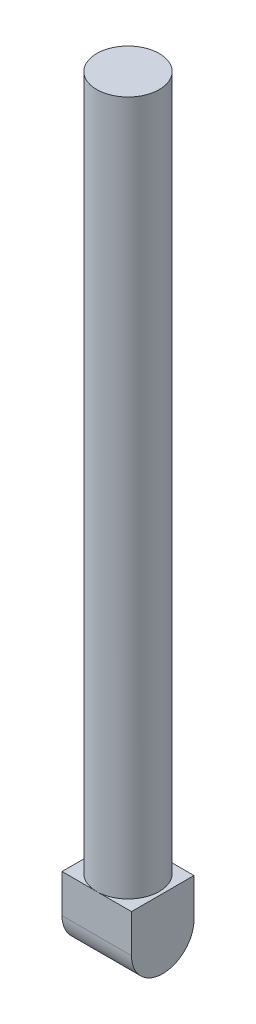
from build123d import *

# Parameters (mm, degrees)
SKETCH_1_W          = 20
SKETCH_1_H          = 18
EXTRUDE_1_DEPTH     = 20
SKETCH_2_R          = 9
EXTRUDE_2_DEPTH     = 200
CUT_EXTRUDE_1_DEPTH = 100


with BuildPart() as part:
    # 草图1 → 凸台-拉伸1 (new body)
    with BuildSketch(Plane(origin=(0, 0, 0), x_dir=(1, 0, 0), z_dir=(0, 1, 0))):
        Rectangle(SKETCH_1_W, SKETCH_1_H)
    extrude(amount=EXTRUDE_1_DEPTH)

    # 草图2 → 凸台-拉伸2 (add)
    with BuildSketch(Plane(origin=(0, 20, 0), x_dir=(1, 0, 0), z_dir=(0, 1, 0))):
        Circle(SKETCH_2_R)
    extrude(amount=EXTRUDE_2_DEPTH)

    # 草图3 → 切除-拉伸1 (cut)
    with BuildSketch(Plane.ZY.offset(10)):
        with BuildLine():
            Line((-9, 9), (-9, -3.669557505))
            Line((-9, -3.669557505), (9, -3.669557505))
            Line((9, -3.669557505), (9, 9))
            ThreePointArc((9, 9), (0, 0), (-9, 9))
        make_face()
    extrude(amount=-CUT_EXTRUDE_1_DEPTH, mode=Mode.SUBTRACT)


solid = part.part
